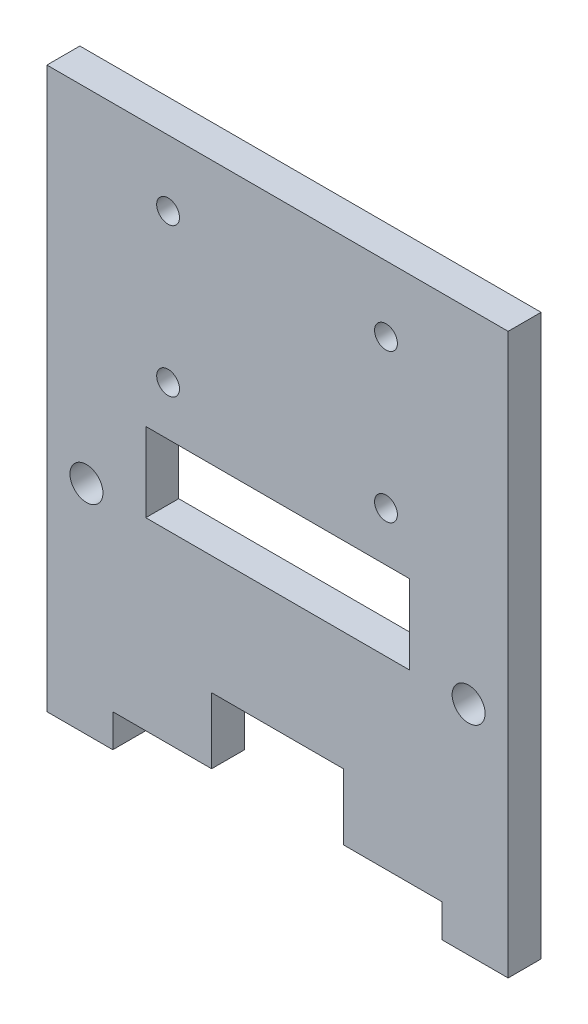
from build123d import *

# Parameters (mm, degrees)
SKETCH1_W           = 44.45
SKETCH1_H           = 53.975
BOSS_EXTRUDE1_DEPTH = 3.175
SKETCH2_W           = 31.75
SKETCH2_H           = 3.175
CUT_EXTRUDE1_DEPTH  = 4.175
SKETCH3_R           = 1.5875
SKETCH3_R_2         = 1.1
SKETCH3_W           = 12.7
SKETCH3_H           = 6.35
SKETCH3_W_2         = 25.4
SKETCH3_H_2         = 7.62
CUT_EXTRUDE2_DEPTH  = 4.175


with BuildPart() as part:
    # Sketch1 → Boss-Extrude1 (new body)
    with BuildSketch(Plane.XY):
        with Locations((22.225, 26.9875)):
            Rectangle(SKETCH1_W, SKETCH1_H)
    extrude(amount=BOSS_EXTRUDE1_DEPTH)

    # Sketch2 → Cut-Extrude1 (cut, through all)
    with BuildSketch(Plane.XY.offset(3.175)):
        with Locations((22.225, 1.5875)):
            Rectangle(SKETCH2_W, SKETCH2_H)
    extrude(amount=-CUT_EXTRUDE1_DEPTH, mode=Mode.SUBTRACT)

    # Sketch3 → Cut-Extrude2 (cut, through all)
    with BuildSketch(Plane.XY.offset(3.175)):
        with Locations((3.81, 20.955)):
            Circle(SKETCH3_R)
        with Locations((40.64, 20.955)):
            Circle(SKETCH3_R)
        with Locations((11.677212596, 47.625)):
            Circle(SKETCH3_R_2)
        with Locations((11.677212596, 33.325)):
            Circle(SKETCH3_R_2)
        with Locations((32.677212596, 47.625)):
            Circle(SKETCH3_R_2)
        with Locations((32.677212596, 33.325)):
            Circle(SKETCH3_R_2)
        with Locations((22.225, 6.35)):
            Rectangle(SKETCH3_W, SKETCH3_H)
        with Locations((22.225, 24.765)):
            Rectangle(SKETCH3_W_2, SKETCH3_H_2)
    extrude(amount=-CUT_EXTRUDE2_DEPTH, mode=Mode.SUBTRACT)


solid = part.part
